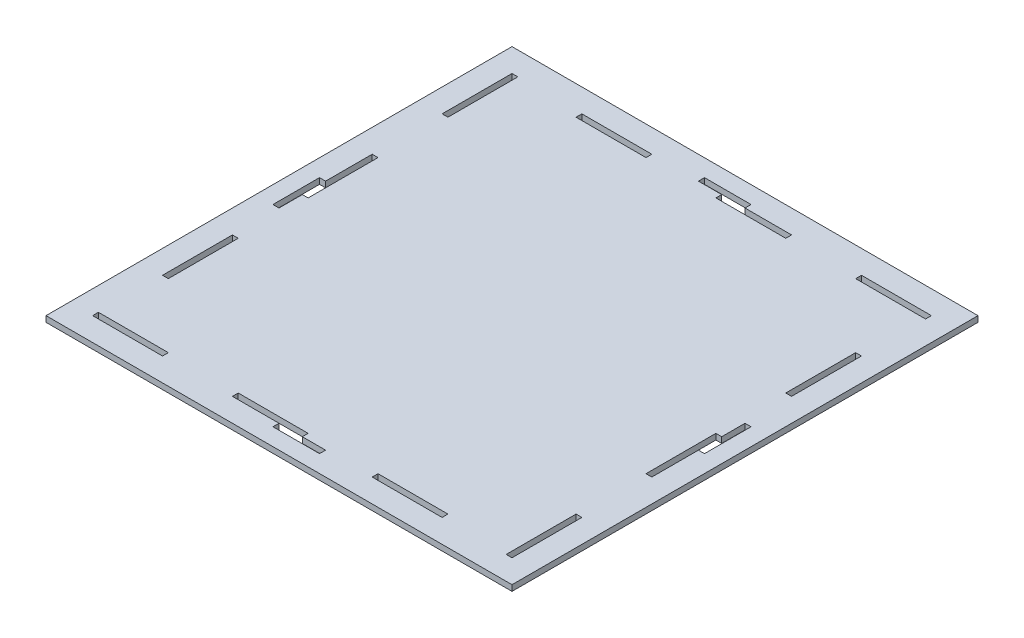
from build123d import *

# Parameters (mm, degrees)
SKETCH1_W           = 254
SKETCH1_H           = 254
SKETCH1_W_2         = 3.175
SKETCH1_H_2         = 38.1
SKETCH1_H_3         = 34.925
SKETCH1_W_3         = 38.1
SKETCH1_H_4         = 3.175
SKETCH1_W_4         = 34.925
BOSS_EXTRUDE1_DEPTH = 3.175


with BuildPart() as part:
    # Sketch1 → Boss-Extrude1 (new body)
    with BuildSketch(Plane(origin=(0, 0, 0), x_dir=(1, 0, 0), z_dir=(0, 1, 0))):
        Rectangle(SKETCH1_W, SKETCH1_H)
        Polygon((-111.125, 114.3), (-76.2, 114.3), (-38.1, 114.3), (-12.7, 114.3), (-12.7, 117.602), (12.7, 117.602), (12.7, 114.3), (38.1, 114.3), (76.2, 114.3), (111.125, 114.3), (114.3, 114.3), (114.3, 111.125), (114.3, 76.2), (114.3, 38.1), (114.3, 12.7), (117.602, 12.7), (117.602, -12.7), (114.3, -12.7), (114.3, -38.1), (114.3, -76.2), (114.3, -111.125), (114.3, -114.3), (111.125, -114.3), (76.2, -114.3), (38.1, -114.3), (12.7, -114.3), (12.7, -117.602), (-12.7, -117.602), (-12.7, -114.3), (-38.1, -114.3), (-76.2, -114.3), (-111.125, -114.3), (-114.3, -114.3), (-114.3, -111.125), (-114.3, -76.2), (-114.3, -38.1), (-114.3, -12.7), (-117.602, -12.7), (-117.602, 12.7), (-114.3, 12.7), (-114.3, 38.1), (-114.3, 76.2), (-114.3, 111.125), (-114.3, 114.3), align=None, mode=Mode.SUBTRACT)
        Polygon((-38.1, 111.125), (-76.2, 111.125), (-111.125, 111.125), (-111.125, 76.2), (-111.125, 38.1), (-111.125, 0), (-111.125, -38.1), (-111.125, -76.2), (-111.125, -111.125), (-76.2, -111.125), (-38.1, -111.125), (0, -111.125), (38.1, -111.125), (76.2, -111.125), (111.125, -111.125), (111.125, -76.2), (111.125, -38.1), (111.125, 0), (111.125, 38.1), (111.125, 76.2), (111.125, 111.125), (76.2, 111.125), (38.1, 111.125), (0, 111.125), align=None)
        with Locations((-112.7125, 57.15)):
            Rectangle(SKETCH1_W_2, SKETCH1_H_2)
        Polygon((-111.125, -38.1), (-111.125, 0), (-114.3, 0), (-114.3, -12.7), (-114.3, -38.1), align=None)
        with Locations((-112.7125, -93.6625)):
            Rectangle(SKETCH1_W_2, SKETCH1_H_3)
        with Locations((-57.15, -112.7125)):
            Rectangle(SKETCH1_W_3, SKETCH1_H_4)
        Polygon((38.1, -111.125), (0, -111.125), (0, -114.3), (12.7, -114.3), (38.1, -114.3), align=None)
        with Locations((93.6625, -112.7125)):
            Rectangle(SKETCH1_W_4, SKETCH1_H_4)
        with Locations((112.7125, -57.15)):
            Rectangle(SKETCH1_W_2, SKETCH1_H_2)
        Polygon((114.3, 38.1), (111.125, 38.1), (111.125, 0), (114.3, 0), (114.3, 12.7), align=None)
        with Locations((112.7125, 93.6625)):
            Rectangle(SKETCH1_W_2, SKETCH1_H_3)
        with Locations((57.15, 112.7125)):
            Rectangle(SKETCH1_W_3, SKETCH1_H_4)
        Polygon((-12.7, 114.3), (-38.1, 114.3), (-38.1, 111.125), (0, 111.125), (0, 114.3), align=None)
        with Locations((-93.6625, 112.7125)):
            Rectangle(SKETCH1_W_4, SKETCH1_H_4)
    extrude(amount=BOSS_EXTRUDE1_DEPTH)


solid = part.part
